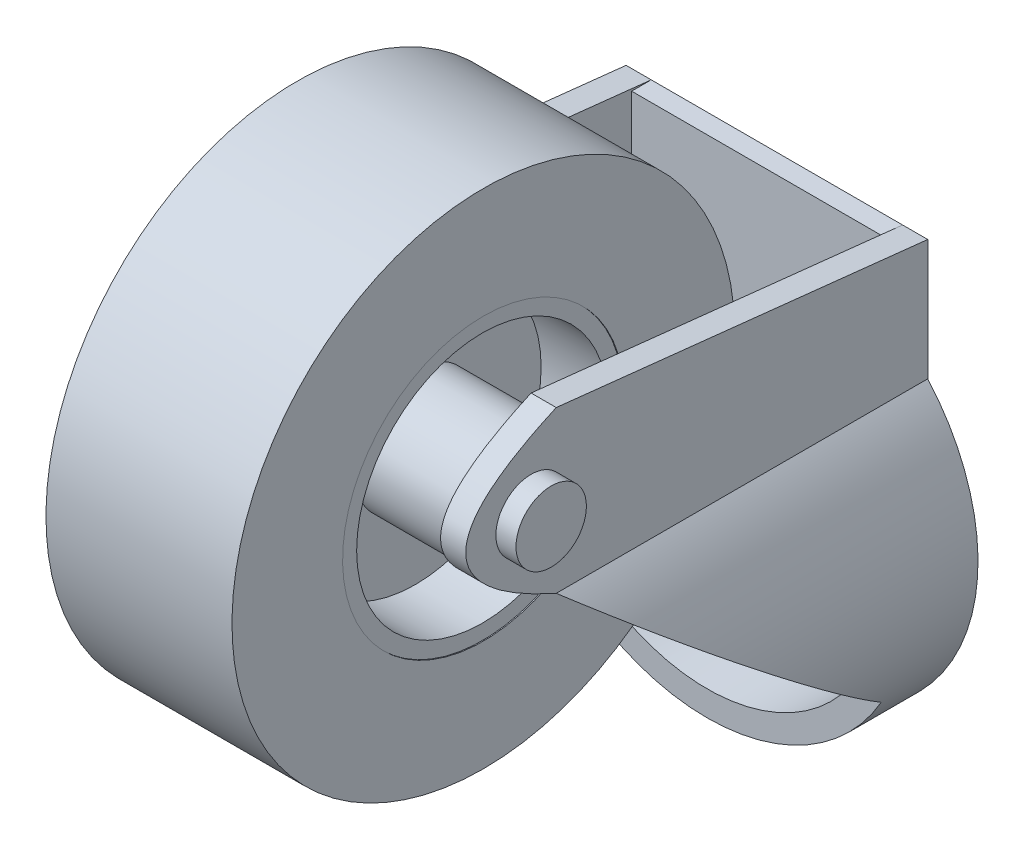
from build123d import *
from build123d.topology import SkipClean

# Parameters (mm, degrees)
SKETCH1_R               = 7.5
BOSS_EXTRUDE1_DEPTH     = 1.95
BOSS_EXTRUDE2_DEPTH     = 5
BOSS_EXTRUDE3_DEPTH     = 40
BOSS_EXTRUDE5_DEPTH     = 2.5
SKETCH20_W              = 10
SKETCH20_H              = 3.999999996
BOSS_EXTRUDE6_DEPTH     = 2.5
BOSS_EXTRUDE7_DEPTH     = 2.5
CUT_EXTRUDE8_DEPTH      = 42.5
CUT_EXTRUDE9_DEPTH      = 42.5
CUT_EXTRUDE9_DEPTH_BACK = 42.5
SKETCH25_R              = 3.5
BOSS_EXTRUDE8_DEPTH     = 2
BOSS_EXTRUDE9_START     = 2
SKETCH26_R              = 3.5
BOSS_EXTRUDE9_DEPTH     = 2
SKETCH27_R              = 6
BOSS_EXTRUDE10_DEPTH    = 12.25
SKETCH33_R              = 25
SKETCH33_R_2            = 12.5
BOSS_EXTRUDE11_DEPTH    = 9.25
SKETCH40_R              = 12.5
BOSS_EXTRUDE13_DEPTH    = 2.5
BOSS_EXTRUDE12_REACH    = 87.153
SKETCH34_R              = 6
CUT_EXTRUDE10_START     = -0.1
SKETCH47_R              = 14
SKETCH47_R_2            = 12.5
CUT_EXTRUDE10_DEPTH     = 0.1
SKETCH48_R              = 14
SKETCH48_R_2            = 12.5
CUT_EXTRUDE13_DEPTH     = 0.1


with BuildPart() as part:
    # Sketch1 → Boss-Extrude1 (new body)
    with BuildSketch(Plane.XY):
        with BuildLine():
            Line((-15.00003653, 25.228715134), (15.00003653, 25.228715134))
            Line((15.00003653, 25.228715134), (15.00003653, 13.228715134))
            ThreePointArc((15.00003653, 13.228715134), (0, -20), (-15.00003653, 13.228715134))
            Line((-15.00003653, 13.228715134), (-15.00003653, 25.228715134))
        make_face()
        Circle(SKETCH1_R, mode=Mode.SUBTRACT)
    extrude(amount=BOSS_EXTRUDE1_DEPTH)

    # Sketch4 → Boss-Extrude2 (add)
    with BuildSketch(Plane.XY.offset(1.95)):
        with BuildLine():
            Line((-12.50003653, 25.228715134), (-12.50003653, 12.247411431))
            ThreePointArc((-12.50003653, 12.247411431), (0, -17.5), (12.50003653, 12.247411431))
            Line((12.50003653, 12.247411431), (12.50003653, 25.228715134))
            Line((12.50003653, 25.228715134), (15.00003653, 25.228715134))
            Line((15.00003653, 25.228715134), (15.00003653, 13.228715134))
            ThreePointArc((15.00003653, 13.228715134), (0, -20), (-15.00003653, 13.228715134))
            Line((-15.00003653, 13.228715134), (-15.00003653, 25.228715134))
            Line((-15.00003653, 25.228715134), (-12.50003653, 25.228715134))
        make_face()
    extrude(amount=BOSS_EXTRUDE2_DEPTH)

    # Sketch7 → Boss-Extrude3 (add)
    with SkipClean():  # the faces are left unmerged after this step: merging them gives an invalid solid
        with BuildSketch(Plane.XY.offset(6.95)):
            with BuildLine():
                Line((-17.320505157, -10.000005055), (-14.361403097, -10.000005055))
                ThreePointArc((-14.361403097, -10.000005055), (-17.439068776, 1.459068274), (-12.50003653, 12.247411431))
                Line((-12.50003653, 12.247411431), (-12.50003653, 15.612465749))
                Line((-12.50003653, 15.612465749), (-12.50003653, 25.228715134))
                Line((-12.50003653, 25.228715134), (-15.00003653, 25.228715134))
                Line((-15.00003653, 25.228715134), (-15.00003653, 13.228715134))
                ThreePointArc((-15.00003653, 13.228715134), (-19.900947569, 1.988035678), (-17.320505157, -10.000005055))
            make_face()
            with BuildLine():
                Line((17.320505157, -10.000005055), (14.361403097, -10.000005055))
                ThreePointArc((14.361403097, -10.000005055), (17.439068776, 1.459068274), (12.50003653, 12.247411431))
                Line((12.50003653, 12.247411431), (12.50003653, 15.612465749))
                Line((12.50003653, 15.612465749), (12.50003653, 25.228715134))
                Line((12.50003653, 25.228715134), (15.00003653, 25.228715134))
                Line((15.00003653, 25.228715134), (15.00003653, 13.228715134))
                ThreePointArc((15.00003653, 13.228715134), (19.900947569, 1.988035678), (17.320505157, -10.000005055))
            make_face()
        extrude(amount=BOSS_EXTRUDE3_DEPTH)

    # Sketch19 → Boss-Extrude5 (add)
    with SkipClean():  # the faces are left unmerged after this step: merging them gives an invalid solid
        with BuildSketch(Plane(origin=(15.00003653, 0, 0), x_dir=(0, 0, -1), z_dir=(1, 0, 0))):
            Polygon((-36.95, 29.22871513), (0, 25.228715134), (-36.95, 25.228715134), align=None)
        extrude(amount=-BOSS_EXTRUDE5_DEPTH)

    # Sketch20 → Boss-Extrude6 (add)
    with SkipClean():  # the faces are left unmerged after this step: merging them gives an invalid solid
        with BuildSketch(Plane(origin=(15.00003653, 0, 0), x_dir=(0, 0, -1), z_dir=(1, 0, 0))):
            with Locations((-41.95, 27.228715132)):
                Rectangle(SKETCH20_W, SKETCH20_H)
        extrude(amount=-BOSS_EXTRUDE6_DEPTH)

    # Sketch22 → Boss-Extrude7 (add)
    with SkipClean():  # the faces are left unmerged after this step: merging them gives an invalid solid
        with BuildSketch(Plane.ZY.offset(15.00003653)):
            Polygon((46.95, 25.228715134), (46.95, 29.22871513), (36.95, 29.22871513), (0, 25.228715134), align=None)
        extrude(amount=-BOSS_EXTRUDE7_DEPTH)

    # Sketch10 → Cut-Extrude8 (cut)
    with SkipClean():  # the faces are left unmerged after this step: merging them gives an invalid solid
        with BuildSketch(Plane(origin=(15.00003653, 0, 0), x_dir=(0, 0, -1), z_dir=(1, 0, 0))):
            with BuildLine():
                Line((-46.95, 25.228715134), (-46.95, 29.22871513))
                Line((-46.95, 29.22871513), (-36.95, 29.22871513))
                add(Edge.make_bspline(
                    [(-36.95, 29.22871513), (-54.95, 21.22871513), (-36.95, 13.228715134)],
                    knots=[0, 0, 0, 1, 1, 1], degree=2))
                Line((-36.95, 13.228715134), (-46.95, 13.228715134))
                Line((-46.95, 13.228715134), (-46.95, 25.228715134))
            make_face()
        extrude(amount=-CUT_EXTRUDE8_DEPTH, mode=Mode.SUBTRACT)

    # Sketch24 → Cut-Extrude9 (cut, two sides: drawn at the far end of the back side and taken through both)
    with SkipClean():  # the faces are left unmerged after this step: merging them gives an invalid solid
        with BuildSketch(Plane(origin=(15.00003653, 0, 0), x_dir=(0, 0, -1), z_dir=(1, 0, 0)).offset(-CUT_EXTRUDE9_DEPTH_BACK)):
            Polygon((-36.95, 13.228715134), (-6.95, -10.000005055), (-46.95, -10.000005055), (-46.95, 13.228715134), align=None)
        extrude(amount=CUT_EXTRUDE9_DEPTH + CUT_EXTRUDE9_DEPTH_BACK, mode=Mode.SUBTRACT)

    # Sketch25 → Boss-Extrude8 (add)
    with SkipClean():  # the faces are left unmerged after this step: merging them gives an invalid solid
        with BuildSketch(Plane.ZY.offset(15.00003653)):
            with Locations((39.45, 21.22871513)):
                Circle(SKETCH25_R)
        extrude(amount=BOSS_EXTRUDE8_DEPTH)

    # Sketch26 → Boss-Extrude9 (add)
    with SkipClean():  # the faces are left unmerged after this step: merging them gives an invalid solid
        with BuildSketch(Plane(origin=(15.00003653, 0, 0), x_dir=(0, 0, -1), z_dir=(1, 0, 0)).offset(BOSS_EXTRUDE9_START)):
            with Locations((-39.45, 21.22871513)):
                Circle(SKETCH26_R)
        extrude(amount=-BOSS_EXTRUDE9_DEPTH)

    # Sketch27 → Boss-Extrude10 (add)
    with SkipClean():  # the faces are left unmerged after this step: merging them gives an invalid solid
        with BuildSketch(Plane.ZY.offset(-12.50003653)):
            with Locations((38.7, 21.22871513)):
                Circle(SKETCH27_R)
        extrude(amount=BOSS_EXTRUDE10_DEPTH)



with BuildPart() as body_2:
    # Sketch33 → Boss-Extrude11 (new, symmetric)
    with BuildSketch(Plane.ZY.offset(-0.25003653)):
        with Locations((38.7, 21.22871513)):
            Circle(SKETCH33_R)
        with Locations((38.7, 21.22871513)):
            Circle(SKETCH33_R_2, mode=Mode.SUBTRACT)
    extrude(amount=BOSS_EXTRUDE11_DEPTH, both=True)


with BuildPart() as part_1:
    with SkipClean():  # the faces are left unmerged after this step: merging them gives an invalid solid
        add(part.part)

        add(body_2.part)  # Boss-Extrude13 merges body 2
        # Sketch40 → Boss-Extrude13 (add, symmetric)
        with BuildSketch(Plane.ZY.offset(-0.25003653)):
            with Locations((38.7, 21.22871513)):
                Circle(SKETCH40_R)
        extrude(amount=BOSS_EXTRUDE13_DEPTH, both=True)

    # Sketch34 → Boss-Extrude12 (add, up to next)
    with BuildSketch(Plane(origin=(-12.50003653, 0, 0), x_dir=(0, 0, -1), z_dir=(1, 0, 0)), mode=Mode.PRIVATE) as boss_extrude12_sk1:
        with Locations((-38.7, 21.22871513)):
            Circle(SKETCH34_R)
    boss_extrude12_tool1 = extrude(boss_extrude12_sk1.sketch, amount=BOSS_EXTRUDE12_REACH, mode=Mode.PRIVATE) - part_1.part
    add(boss_extrude12_tool1.solids().sort_by_distance((-12.500037, 21.228715, 38.7))[0])

    # Sketch47 → Cut-Extrude10 (cut)
    with SkipClean():  # the faces are left unmerged after this step: merging them gives an invalid solid
        with BuildSketch(Plane.ZY.offset(8.99996347).offset(CUT_EXTRUDE10_START)):
            with Locations((38.7, 21.22871513)):
                Circle(SKETCH47_R)
            with Locations((38.7, 21.22871513)):
                Circle(SKETCH47_R_2, mode=Mode.SUBTRACT)
        extrude(amount=CUT_EXTRUDE10_DEPTH, mode=Mode.SUBTRACT)

    # Sketch48 → Cut-Extrude13 (cut)
    with SkipClean():  # the faces are left unmerged after this step: merging them gives an invalid solid
        with BuildSketch(Plane(origin=(9.50003653, 0, 0), x_dir=(0, 0, -1), z_dir=(1, 0, 0))):
            with Locations((-38.7, 21.22871513)):
                Circle(SKETCH48_R)
            with Locations((-38.7, 21.22871513)):
                Circle(SKETCH48_R_2, mode=Mode.SUBTRACT)
        extrude(amount=-CUT_EXTRUDE13_DEPTH, mode=Mode.SUBTRACT)


solid = part_1.part
